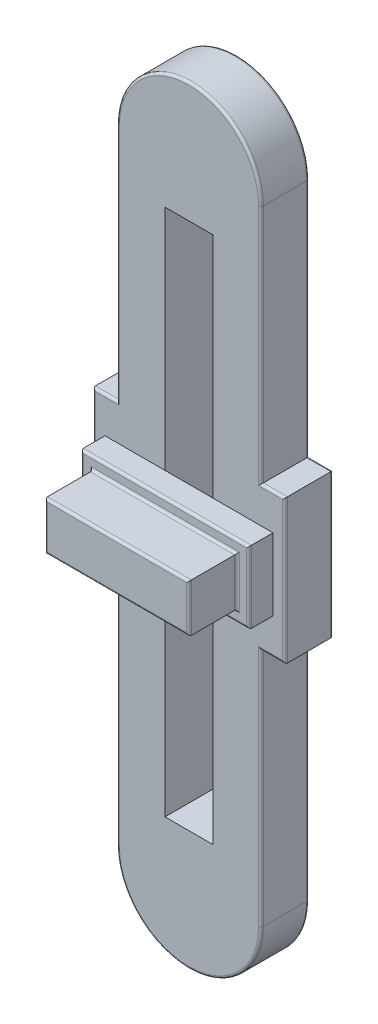
from build123d import *

# Parameters (mm, degrees)
SKETCH1_W           = 20
SKETCH1_H           = 220
BOSS_EXTRUDE1_DEPTH = 20
SKETCH2_W           = 60
SKETCH2_H           = 20
BOSS_EXTRUDE2_DEPTH = 30
SKETCH3_W           = 70
SKETCH3_H           = 30
SKETCH3_W_2         = 60
SKETCH3_H_2         = 20
BOSS_EXTRUDE3_DEPTH = 10
FILLET1_R           = 1
FILLET2_R           = 1


with BuildPart() as part:
    # Sketch1 → Boss-Extrude1 (new body)
    with BuildSketch(Plane.XY):
        with BuildLine():
            Line((30, 0), (30, -100))
            Line((30, -100), (40, -100))
            Line((40, -100), (40, -160))
            Line((40, -160), (30, -160))
            Line((30, -160), (30, -260))
            ThreePointArc((30, -260), (0, -290), (-30, -260))
            Line((-30, -260), (-30, -160))
            Line((-30, -160), (-40, -160))
            Line((-40, -160), (-40, -100))
            Line((-40, -100), (-30, -100))
            Line((-30, -100), (-30, 0))
            ThreePointArc((-30, 0), (0, 30), (30, 0))
        make_face()
        with Locations((0, -130)):
            Rectangle(SKETCH1_W, SKETCH1_H, mode=Mode.SUBTRACT)
    extrude(amount=BOSS_EXTRUDE1_DEPTH)

    # Sketch2 → Boss-Extrude2 (add)
    with BuildSketch(Plane.XY.offset(20)):
        with Locations((0, -130)):
            Rectangle(SKETCH2_W, SKETCH2_H)
    extrude(amount=BOSS_EXTRUDE2_DEPTH)

    # Sketch3 → Boss-Extrude3 (add)
    with BuildSketch(Plane.XY.offset(20)):
        with Locations((0, -130)):
            Rectangle(SKETCH3_W, SKETCH3_H)
        with Locations((0, -130)):
            Rectangle(SKETCH3_W_2, SKETCH3_H_2, mode=Mode.SUBTRACT)
    extrude(amount=BOSS_EXTRUDE3_DEPTH)

    # Fillet1
    fillet1_edges = [part.edges().sort_by_distance(p)[0] for p in [
        (-30, -130, 50),
        (0, -140, 50),
        (30, -130, 50),
        (0, -120, 50),
        (35, -130, 30),
        (0, -115, 30),
        (-35, -130, 30),
        (0, -145, 30),
        (0, -120, 30),
        (-30, -130, 30),
        (0, -140, 30),
        (30, -130, 30),
    ]]
    fillet(fillet1_edges, radius=FILLET1_R)

    # Fillet2
    fillet2_edges = [part.edges().sort_by_distance(p)[0] for p in [
        (30, -50, 0),
        (35, -100, 0),
        (-35, -100, 20),
        (40, -130, 0),
        (35, -160, 0),
        (30, -210, 0),
        (0, -290, 0),
        (-30, -210, 0),
        (-35, -160, 0),
        (-40, -130, 0),
        (-35, -100, 0),
        (-30, -50, 0),
        (0, 30, 0),
        (-40, -130, 20),
        (-35, -160, 20),
        (-30, -210, 20),
        (0, -290, 20),
        (30, -210, 20),
        (35, -160, 20),
        (40, -130, 20),
        (35, -100, 20),
        (30, -50, 20),
        (0, 30, 20),
        (-30, -50, 20),
    ]]
    fillet(fillet2_edges, radius=FILLET2_R)


solid = part.part
